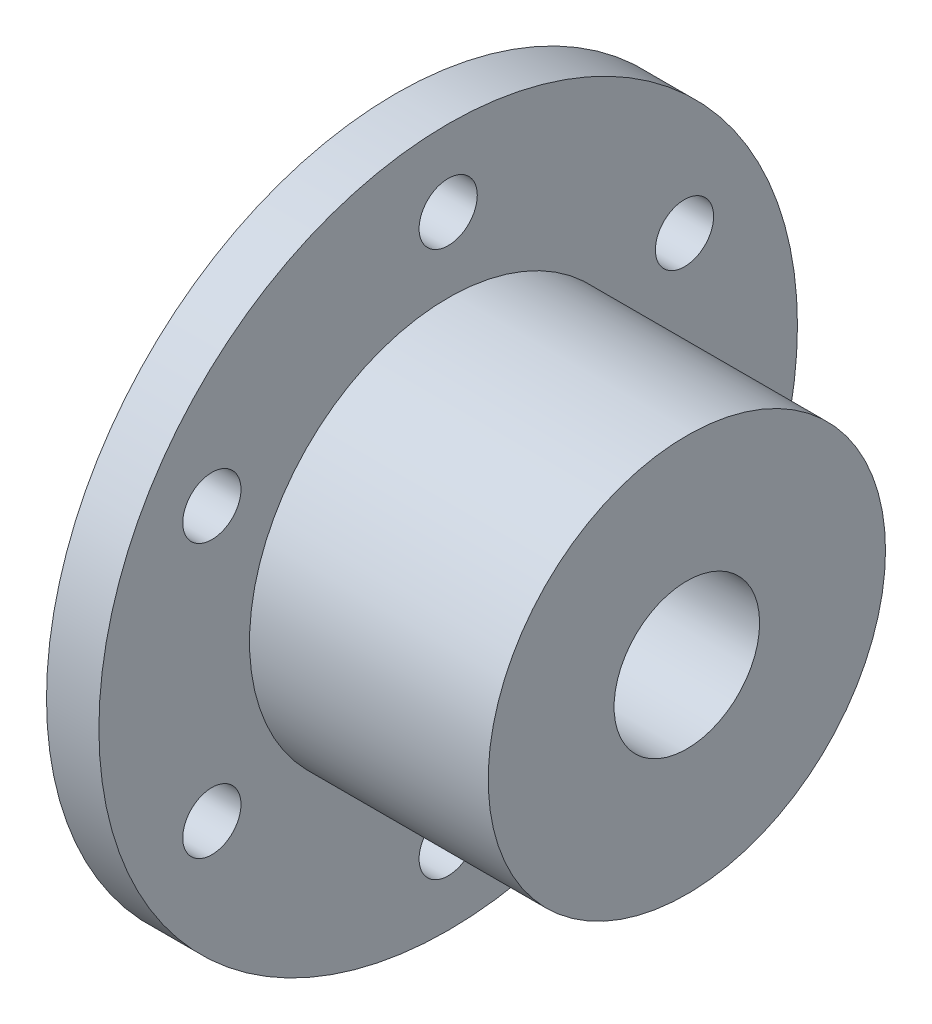
from build123d import *

# Parameters (mm, degrees)
SKETCH1_R           = 30.48
SKETCH1_R_2         = 6.35
SKETCH1_R_3         = 2.54
BOSS_EXTRUDE1_DEPTH = 12.7
SKETCH2_OUTSIDE_W   = 80.934
SKETCH2_OUTSIDE_H   = 80.934
SKETCH2_OUTSIDE_R   = 17.3355
CUT_EXTRUDE1_DEPTH  = 20.828


with BuildPart() as part:
    # Sketch1 → Boss-Extrude1 (new body, symmetric)
    with BuildSketch(Plane(origin=(0, 0, 0), x_dir=(0, 0, -1), z_dir=(1, 0, 0))):
        Circle(SKETCH1_R)
        Circle(SKETCH1_R_2, mode=Mode.SUBTRACT)
        with Locations((0, 23.8125)):
            Circle(SKETCH1_R_3, mode=Mode.SUBTRACT)
        with Locations((20.622229928, 11.90625)):
            Circle(SKETCH1_R_3, mode=Mode.SUBTRACT)
        with Locations((20.622229928, -11.90625)):
            Circle(SKETCH1_R_3, mode=Mode.SUBTRACT)
        with Locations((0, -23.8125)):
            Circle(SKETCH1_R_3, mode=Mode.SUBTRACT)
        with Locations((-20.622229928, -11.90625)):
            Circle(SKETCH1_R_3, mode=Mode.SUBTRACT)
        with Locations((-20.622229928, 11.90625)):
            Circle(SKETCH1_R_3, mode=Mode.SUBTRACT)
    extrude(amount=BOSS_EXTRUDE1_DEPTH, both=True)

    # Sketch2 outside → Cut-Extrude1 (cut)
    with BuildSketch(Plane(origin=(12.7, 0, 0), x_dir=(0, 0, -1), z_dir=(1, 0, 0))):
        Rectangle(SKETCH2_OUTSIDE_W, SKETCH2_OUTSIDE_H)
        Circle(SKETCH2_OUTSIDE_R, mode=Mode.SUBTRACT)
    extrude(amount=-CUT_EXTRUDE1_DEPTH, mode=Mode.SUBTRACT)


solid = part.part
